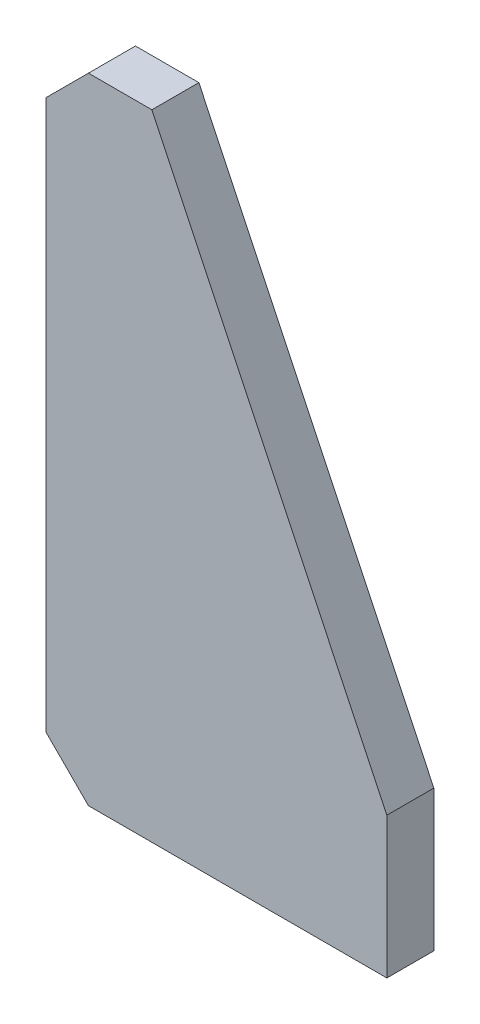
from build123d import *

# Parameters (mm, degrees)
EXTRUDE_1_DEPTH = 20


with BuildPart() as part:
    # Эскиз1 → Бобышка-Вытянуть1 (new body)
    with BuildSketch(Plane.XY):
        Polygon((0, 0), (0, 60), (-100, 270), (-127, 270), (-145, 252), (-145, 18), (-127, 0), align=None)
    extrude(amount=EXTRUDE_1_DEPTH)


solid = part.part
